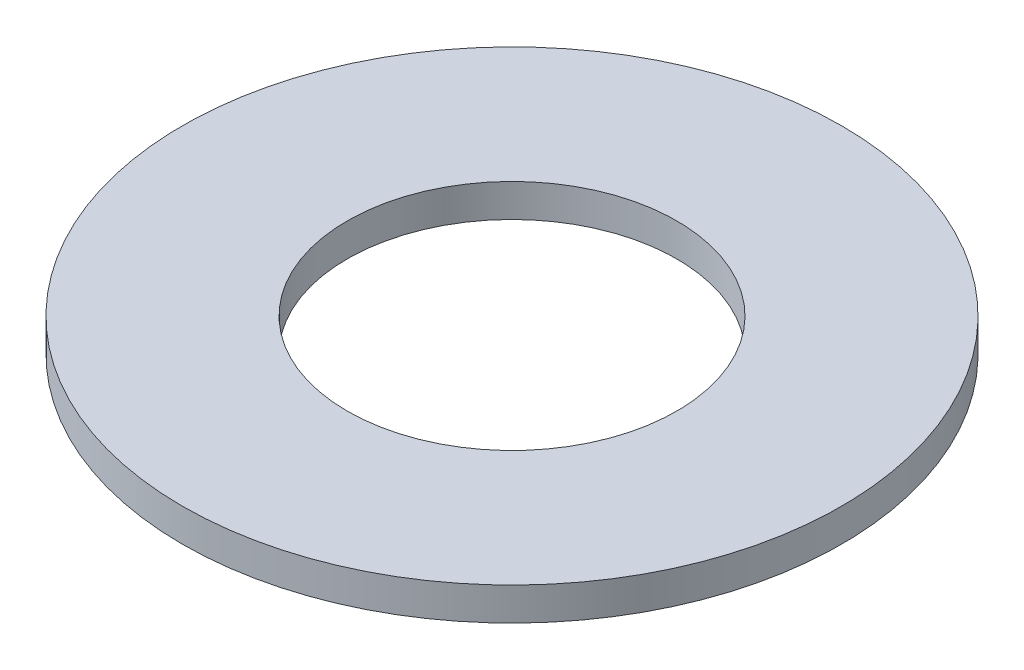
from build123d import *

# Parameters (mm, degrees)
SKETCH1_R           = 10
SKETCH1_R_2         = 5
BOSS_EXTRUDE1_DEPTH = 1


with BuildPart() as part:
    # Sketch1 → Boss-Extrude1 (new body)
    with BuildSketch(Plane(origin=(0, 0, 0), x_dir=(1, 0, 0), z_dir=(0, 1, 0))):
        Circle(SKETCH1_R)
        Circle(SKETCH1_R_2, mode=Mode.SUBTRACT)
    extrude(amount=-BOSS_EXTRUDE1_DEPTH)


solid = part.part
